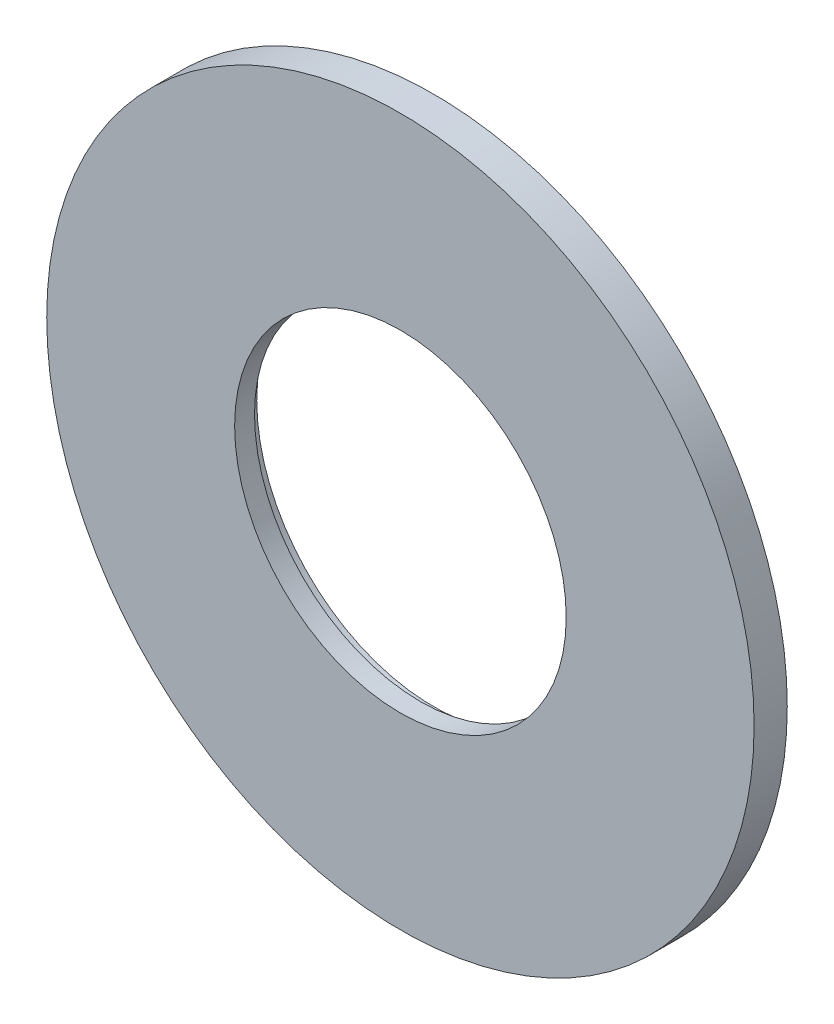
from build123d import *

# Parameters (mm, degrees)
SCHIZZO1_R                   = 16
SCHIZZO1_R_2                 = 8
ESTRUSIONE_ESTRUSIONE1_DEPTH = 0.6
SCHIZZO3_R                   = 16
SCHIZZO3_R_2                 = 7.5
ESTRUSIONE_ESTRUSIONE2_DEPTH = 0.9
SCHIZZO5_R                   = 1.45
ESTRUSIONE_ESTRUSIONE3_DEPTH = 1
RIPETIZIONECIRCOLARE1_COUNT  = 4


with BuildPart() as part:
    # Schizzo1 → Estrusione-Estrusione1 (new body)
    with BuildSketch(Plane.XY):
        Circle(SCHIZZO1_R)
        Circle(SCHIZZO1_R_2, mode=Mode.SUBTRACT)
    extrude(amount=ESTRUSIONE_ESTRUSIONE1_DEPTH)

    # Schizzo3 → Estrusione-Estrusione2 (add)
    with BuildSketch(Plane.XY.offset(0.6)):
        Circle(SCHIZZO3_R)
        Circle(SCHIZZO3_R_2, mode=Mode.SUBTRACT)
    extrude(amount=ESTRUSIONE_ESTRUSIONE2_DEPTH)

    # Schizzo5 → Estrusione-Estrusione3 (add)
    with BuildSketch(Plane(origin=(0, 0, 0), x_dir=(-1, 0, 0), z_dir=(0, 0, -1))):
        with Locations((0, 12.5)):
            Circle(SCHIZZO5_R)
    estrusione_estrusione3 = extrude(amount=ESTRUSIONE_ESTRUSIONE3_DEPTH)

    # RipetizioneCircolare1: Estrusione-Estrusione3 ×4 about axis
    ripetizionecircolare1_axis = Axis((0, 0, 0), (0, 0, 1))
    for i in range(1, RIPETIZIONECIRCOLARE1_COUNT):
        add(estrusione_estrusione3.rotate(ripetizionecircolare1_axis, i * 360 / RIPETIZIONECIRCOLARE1_COUNT))


solid = part.part
